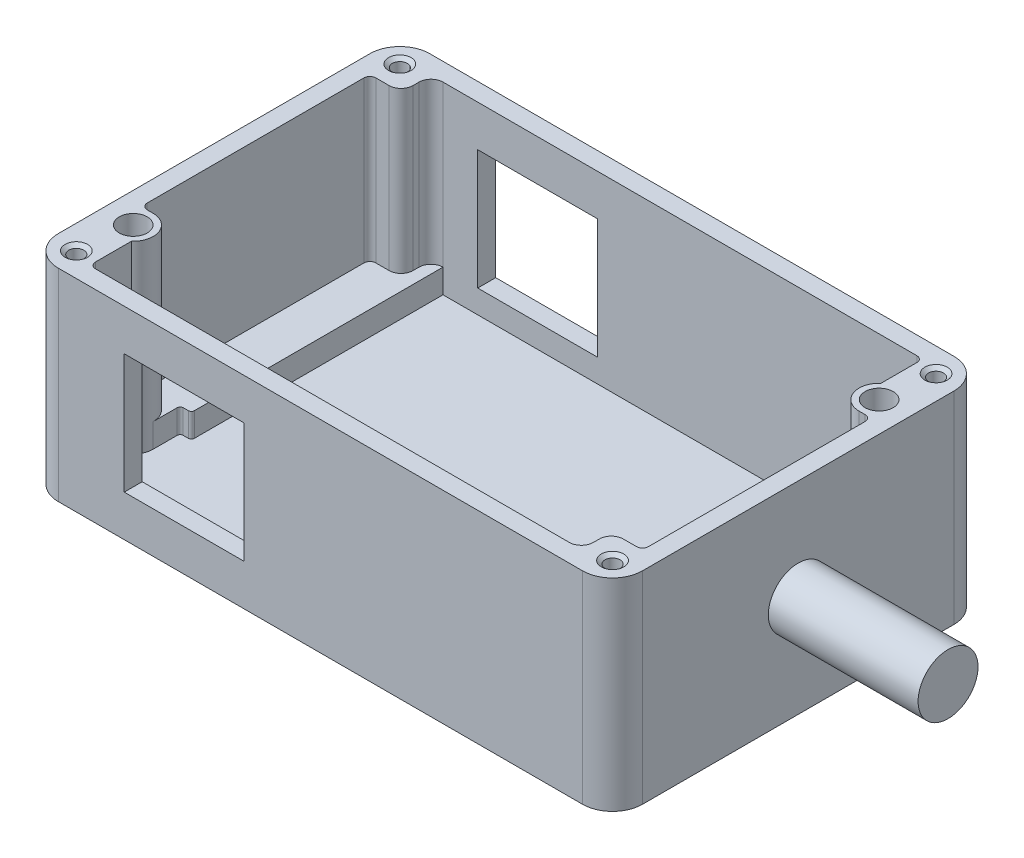
from build123d import *

# Parameters (mm, degrees)
BOSS_EXTRUDE1_DEPTH                               = 42.8625
CSK_FOR_0_FLAT_HEAD_MACHINE_SCREW_100_D           = 3.175
CSK_FOR_0_FLAT_HEAD_MACHINE_SCREW_100_CSINK_D     = 4.7625
CSK_FOR_0_FLAT_HEAD_MACHINE_SCREW_100_CSINK_ANGLE = 100
A_0_234_DIAMETER_HOLE1_D                          = 5.9436
A_0_234_DIAMETER_HOLE1_DEPTH                      = 42.8625
CUT_EXTRUDE1_DEPTH                                = 39.0525
BOSS_EXTRUDE2_DEPTH                               = 5.08
SKETCH12_W                                        = 25.4
SKETCH12_H                                        = 25.4
CUT_EXTRUDE2_DEPTH                                = 79.74
SKETCH13_R                                        = 6.35
BOSS_EXTRUDE3_DEPTH                               = 31.75


with BuildPart() as part:
    # Sketch1 → Boss-Extrude1 (new body)
    with BuildSketch(Plane(origin=(0, 0, 0), x_dir=(1, 0, 0), z_dir=(0, 1, 0))):
        with BuildLine():
            Line((6.35, 0), (117.475, 0))
            ThreePointArc((117.475, 0), (121.965128061, 1.859871939), (123.825, 6.35))
            Line((123.825, 6.35), (123.825, 72.39))
            ThreePointArc((123.825, 72.39), (121.965128061, 76.880128061), (117.475, 78.74))
            Line((117.475, 78.74), (6.35, 78.74))
            ThreePointArc((6.35, 78.74), (1.859871939, 76.880128061), (0, 72.39))
            Line((0, 72.39), (0, 6.35))
            ThreePointArc((0, 6.35), (1.859871939, 1.859871939), (6.35, 0))
        make_face()
    extrude(amount=BOSS_EXTRUDE1_DEPTH)

    # CSK for #0 Flat Head Machine Screw (100)1 (through all)
    with Locations(Plane(origin=(0, 42.8625, 0), x_dir=(1, 0, 0), z_dir=(0, 1, 0))):
        with Locations((5.08, 5.08), (5.08, 73.66), (118.745, 73.66), (118.745, 5.08)):
            CounterSinkHole(CSK_FOR_0_FLAT_HEAD_MACHINE_SCREW_100_D / 2, CSK_FOR_0_FLAT_HEAD_MACHINE_SCREW_100_CSINK_D / 2, counter_sink_angle=CSK_FOR_0_FLAT_HEAD_MACHINE_SCREW_100_CSINK_ANGLE)

    # A (0.234) Diameter Hole1
    with Locations(Plane(origin=(0, 42.8625, 0), x_dir=(1, 0, 0), z_dir=(0, 1, 0))):
        with Locations((6.35, 15.875), (117.475, 62.865)):
            Hole(A_0_234_DIAMETER_HOLE1_D / 2, depth=A_0_234_DIAMETER_HOLE1_DEPTH)

    # Sketch9 → Cut-Extrude1 (cut)
    with BuildSketch(Plane(origin=(0, 42.8625, 0), x_dir=(1, 0, 0), z_dir=(0, 1, 0))):
        with BuildLine():
            Line((5.08, 68.58), (7.880598047, 68.58))
            ThreePointArc((7.880598047, 68.58), (9.676649271, 69.323948776), (10.420598047, 71.12))
            Line((10.420598047, 71.12), (10.420598047, 72.39))
            ThreePointArc((10.420598047, 72.39), (11.164546822, 74.186051224), (12.960598047, 74.93))
            Line((12.960598047, 74.93), (61.9125, 74.93))
            Line((61.9125, 74.93), (113.404401953, 74.93))
            ThreePointArc((113.404401953, 74.93), (114.302427566, 74.558025612), (114.674401953, 73.66))
            Line((114.674401953, 73.66), (114.674401953, 66.05083079))
            ThreePointArc((114.674401953, 66.05083079), (113.505962063, 61.368468979), (117.475, 58.6232))
            Line((117.475, 58.6232), (118.745, 58.6232))
            ThreePointArc((118.745, 58.6232), (119.643025612, 58.251225612), (120.015, 57.3532))
            Line((120.015, 57.3532), (120.015, 11.43))
            ThreePointArc((120.015, 11.43), (119.643025612, 10.531974388), (118.745, 10.16))
            Line((118.745, 10.16), (115.944401953, 10.16))
            ThreePointArc((115.944401953, 10.16), (114.148350729, 9.416051224), (113.404401953, 7.62))
            Line((113.404401953, 7.62), (113.404401953, 6.35))
            ThreePointArc((113.404401953, 6.35), (112.660453178, 4.553948776), (110.864401953, 3.81))
            Line((110.864401953, 3.81), (61.9125, 3.81))
            Line((61.9125, 3.81), (10.420598047, 3.81))
            ThreePointArc((10.420598047, 3.81), (9.522572434, 4.181974388), (9.150598047, 5.08))
            Line((9.150598047, 5.08), (9.150598047, 12.68916921))
            ThreePointArc((9.150598047, 12.68916921), (10.319037937, 17.371531021), (6.35, 20.1168))
            Line((6.35, 20.1168), (5.08, 20.1168))
            ThreePointArc((5.08, 20.1168), (4.181974388, 20.488774388), (3.81, 21.3868))
            Line((3.81, 21.3868), (3.81, 67.31))
            ThreePointArc((3.81, 67.31), (4.181974388, 68.208025612), (5.08, 68.58))
        make_face()
    extrude(amount=-CUT_EXTRUDE1_DEPTH, mode=Mode.SUBTRACT)

    # Sketch11 → Boss-Extrude2 (add)
    with BuildSketch(Plane(origin=(0, 3.81, 0), x_dir=(1, 0, 0), z_dir=(0, 1, 0))):
        with BuildLine():
            Line((12.960598047, 74.93), (12.960598047, 22.225))
            ThreePointArc((12.960598047, 22.225), (12.774610853, 21.775987194), (12.325598047, 21.59))
            Line((12.325598047, 21.59), (11.2268, 21.59))
            ThreePointArc((11.2268, 21.59), (10.777787194, 21.404012806), (10.5918, 20.955))
            Line((10.5918, 20.955), (10.5918, 15.875))
            ThreePointArc((10.5918, 15.875), (9.349405544, 18.874405544), (6.35, 20.1168))
            Line((6.35, 20.1168), (5.08, 20.1168))
            ThreePointArc((5.08, 20.1168), (4.181974388, 20.488774388), (3.81, 21.3868))
            Line((3.81, 21.3868), (3.81, 67.31))
            ThreePointArc((3.81, 67.31), (4.181974388, 68.208025612), (5.08, 68.58))
            Line((5.08, 68.58), (7.880598047, 68.58))
            ThreePointArc((7.880598047, 68.58), (9.676649271, 69.323948776), (10.420598047, 71.12))
            Line((10.420598047, 71.12), (10.420598047, 72.39))
            ThreePointArc((10.420598047, 72.39), (11.164546822, 74.186051224), (12.960598047, 74.93))
        make_face()
        with BuildLine():
            Line((110.864401953, 3.81), (110.864401953, 56.515))
            ThreePointArc((110.864401953, 56.515), (111.050389147, 56.964012806), (111.499401953, 57.15))
            Line((111.499401953, 57.15), (112.5982, 57.15))
            ThreePointArc((112.5982, 57.15), (113.047212806, 57.335987194), (113.2332, 57.785))
            Line((113.2332, 57.785), (113.2332, 62.865))
            ThreePointArc((113.2332, 62.865), (114.475594456, 59.865594456), (117.475, 58.6232))
            Line((117.475, 58.6232), (118.745, 58.6232))
            ThreePointArc((118.745, 58.6232), (119.643025612, 58.251225612), (120.015, 57.3532))
            Line((120.015, 57.3532), (120.015, 11.43))
            ThreePointArc((120.015, 11.43), (119.643025612, 10.531974388), (118.745, 10.16))
            Line((118.745, 10.16), (115.944401953, 10.16))
            ThreePointArc((115.944401953, 10.16), (114.148350729, 9.416051224), (113.404401953, 7.62))
            Line((113.404401953, 7.62), (113.404401953, 6.35))
            ThreePointArc((113.404401953, 6.35), (112.660453178, 4.553948776), (110.864401953, 3.81))
        make_face()
    extrude(amount=BOSS_EXTRUDE2_DEPTH)

    # Sketch12 → Cut-Extrude2 (cut, through all)
    with BuildSketch(Plane(origin=(0, 0, -78.74), x_dir=(-1, 0, 0), z_dir=(0, 0, -1))):
        with Locations((-33.02, 21.43125)):
            Rectangle(SKETCH12_W, SKETCH12_H)
    extrude(amount=-CUT_EXTRUDE2_DEPTH, mode=Mode.SUBTRACT)

    # Sketch13 → Boss-Extrude3 (add)
    with BuildSketch(Plane(origin=(123.825, 0, 0), x_dir=(0, 0, -1), z_dir=(1, 0, 0))):
        with Locations((39.37, 21.43125)):
            Circle(SKETCH13_R)
    extrude(amount=BOSS_EXTRUDE3_DEPTH)


solid = part.part
